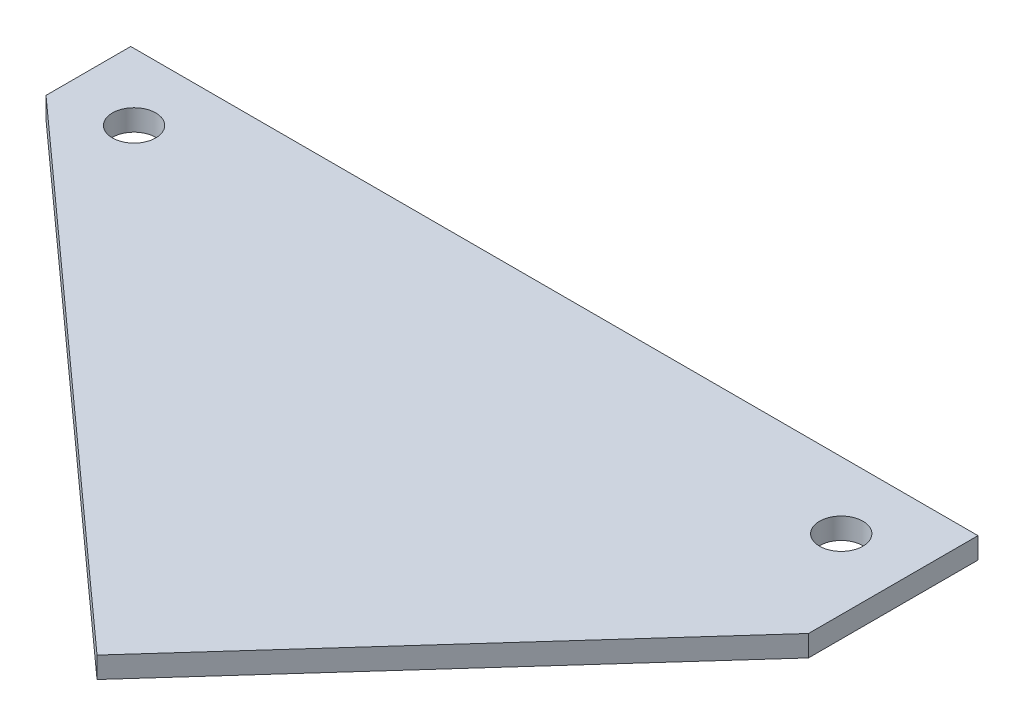
from build123d import *

# Parameters (mm, degrees)
SKETCH1_W           = 127
SKETCH1_H           = 127
BOSS_EXTRUDE1_DEPTH = 3.175
SKETCH2_R           = 3.25
CUT_EXTRUDE1_DEPTH  = 4.175


with BuildPart() as part:
    # Sketch1 → Boss-Extrude1 (new body)
    with BuildSketch(Plane(origin=(0, 0, 0), x_dir=(1, 0, 0), z_dir=(0, 1, 0))):
        with Locations((0, -25.4)):
            Rectangle(SKETCH1_W, SKETCH1_H)
    extrude(amount=BOSS_EXTRUDE1_DEPTH)

    # Sketch2 → Cut-Extrude1 (cut, through all)
    with BuildSketch(Plane(origin=(0, 3.175, 0), x_dir=(1, 0, 0), z_dir=(0, 1, 0))):
        Polygon((12.980662983, -43.432596685), (-63.5, 25.4), (-63.5, -88.9), (63.5, -88.9), (63.5, 12.7), align=None)
        with Locations((53, 28.1)):
            Circle(SKETCH2_R)
        with Locations((-53, 28.1)):
            Circle(SKETCH2_R)
    extrude(amount=-CUT_EXTRUDE1_DEPTH, mode=Mode.SUBTRACT)


solid = part.part
